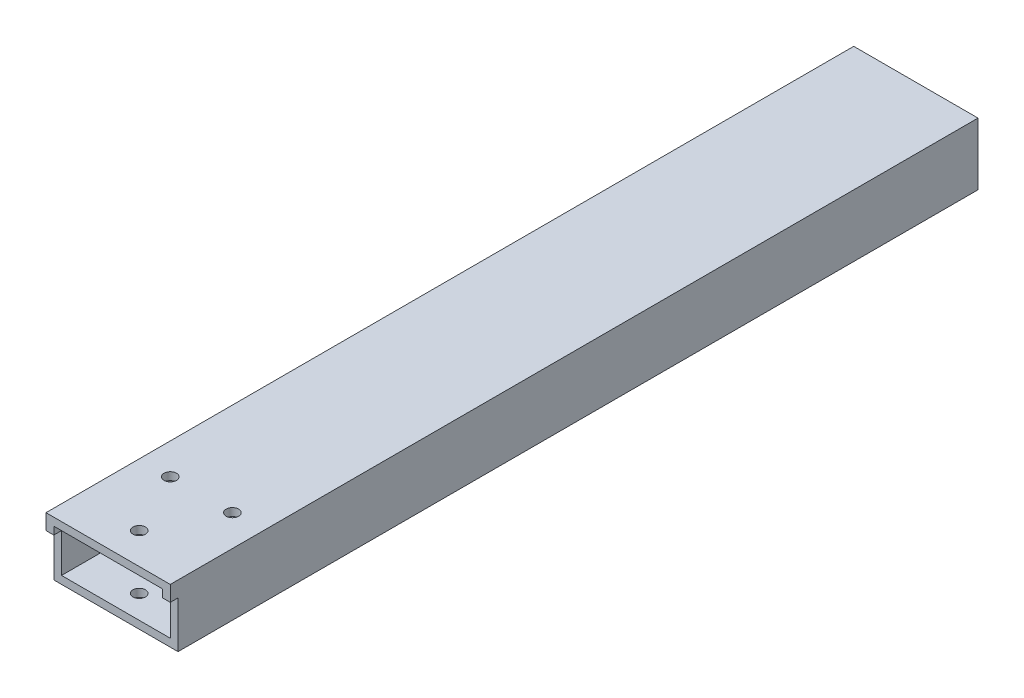
from build123d import *

# Parameters (mm, degrees)
SKETCH1_W           = 50.8
SKETCH1_H           = 25.4
SKETCH1_W_2         = 44.45
SKETCH1_H_2         = 19.05
BOSS_EXTRUDE1_DEPTH = 330.2
SKETCH2_W           = 50.8
SKETCH2_H           = 19.05
CUT_EXTRUDE1_DEPTH  = 3.175
SKETCH3_R           = 2.5527
CUT_EXTRUDE2_DEPTH  = 44.45


with BuildPart() as part:
    # Sketch1 → Boss-Extrude1 (new body)
    with BuildSketch(Plane.XY):
        with Locations((25.4, 12.7)):
            Rectangle(SKETCH1_W, SKETCH1_H)
        with Locations((25.4, 12.7)):
            Rectangle(SKETCH1_W_2, SKETCH1_H_2, mode=Mode.SUBTRACT)
    extrude(amount=BOSS_EXTRUDE1_DEPTH)

    # Sketch2 → Cut-Extrude1 (cut)
    with BuildSketch(Plane.XY.offset(330.2)):
        with Locations((25.4, 9.525)):
            Rectangle(SKETCH2_W, SKETCH2_H)
    extrude(amount=-CUT_EXTRUDE1_DEPTH, mode=Mode.SUBTRACT)

    # Sketch3 → Cut-Extrude2 (cut)
    with BuildSketch(Plane(origin=(0, 25.4, 0), x_dir=(1, 0, 0), z_dir=(0, 1, 0))):
        with Locations((12.7, -292.1)):
            Circle(SKETCH3_R)
        with Locations((38.1, -292.1)):
            Circle(SKETCH3_R)
        with Locations((25.4, -317.5)):
            Circle(SKETCH3_R)
    extrude(amount=-CUT_EXTRUDE2_DEPTH, mode=Mode.SUBTRACT)


solid = part.part
